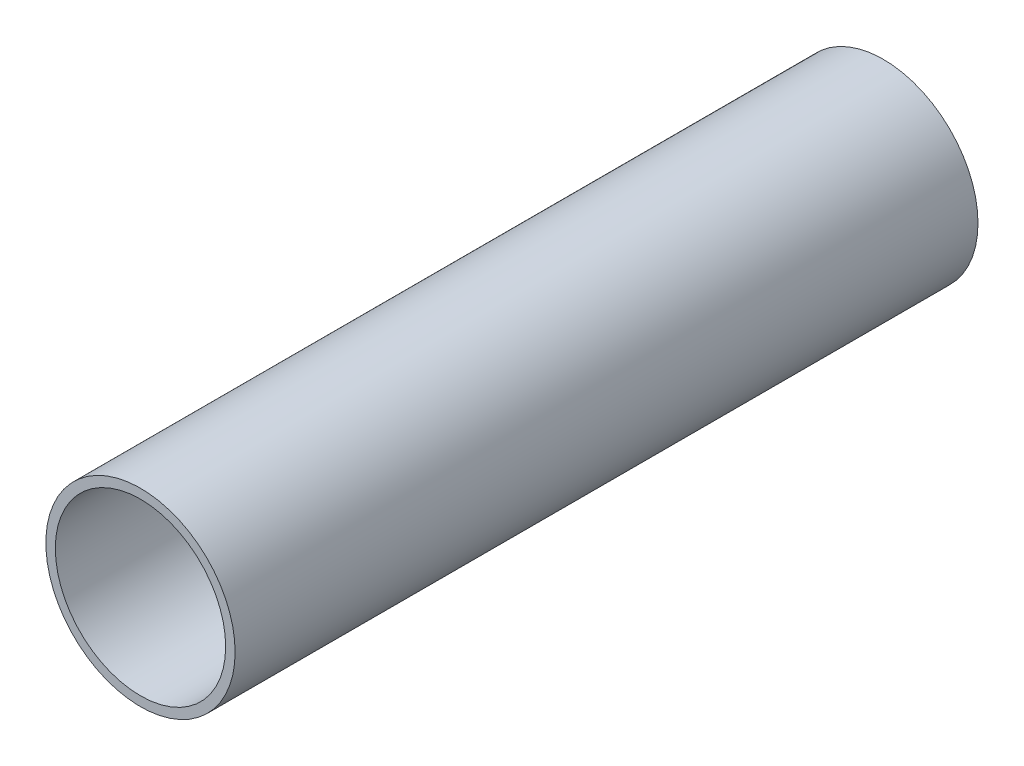
from build123d import *

# Parameters (mm, degrees)
SKETCH1_R           = 20
SKETCH1_R_2         = 18
BOSS_EXTRUDE1_DEPTH = 157


with BuildPart() as part:
    # Sketch1 → Boss-Extrude1 (new body)
    with BuildSketch(Plane.XY):
        Circle(SKETCH1_R)
        Circle(SKETCH1_R_2, mode=Mode.SUBTRACT)
    extrude(amount=BOSS_EXTRUDE1_DEPTH)


solid = part.part
